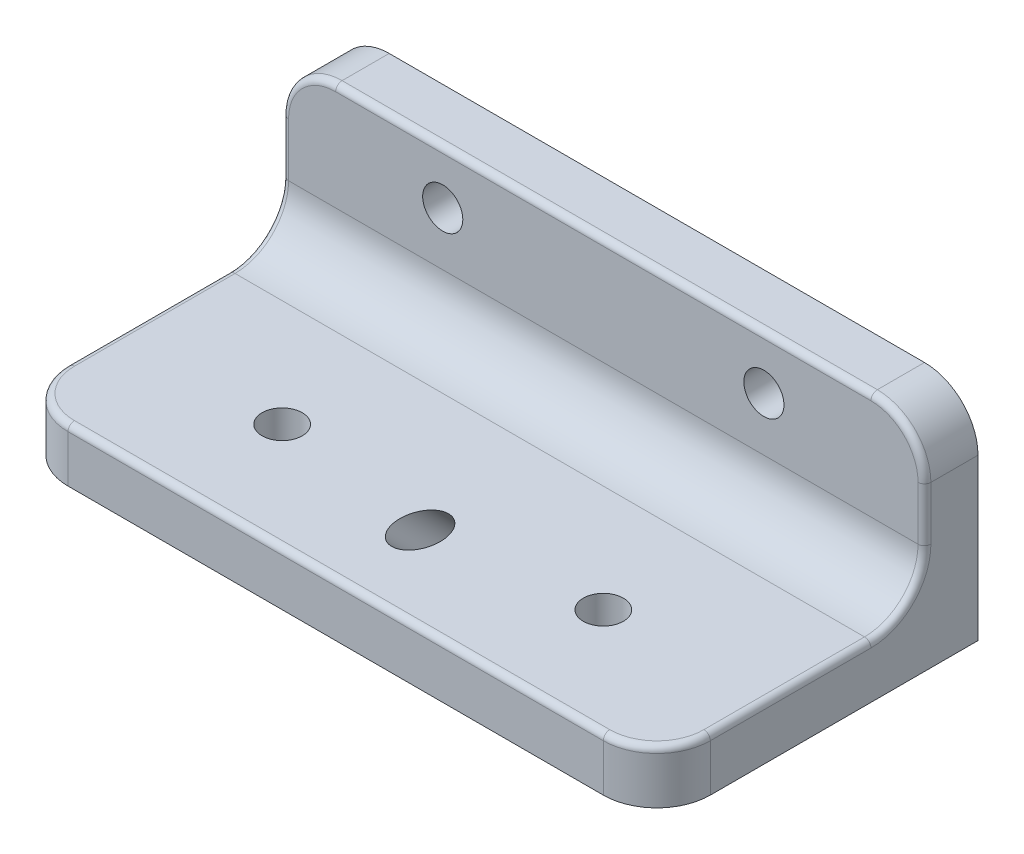
from build123d import *

# Parameters (mm, degrees)
SKETCH1_W           = 38.1
SKETCH1_H           = 12.7
SKETCH1_R           = 1.190625
BOSS_EXTRUDE1_DEPTH = 3.175
SKETCH2_W           = 38.1
SKETCH2_H           = 15.875
BOSS_EXTRUDE2_DEPTH = 3.175
FILLET1_R           = 3.175
FILLET2_R           = 0.381
SKETCH3_R           = 1.190625
CUT_EXTRUDE1_DEPTH  = 16.557632845
SKETCH4_R           = 1.190625
CUT_EXTRUDE2_DEPTH  = 13.7


with BuildPart() as part:
    # Sketch1 → Boss-Extrude1 (new body)
    with BuildSketch(Plane.XY):
        with Locations((19.05, -6.35)):
            Rectangle(SKETCH1_W, SKETCH1_H)
        with Locations((9.525, -3.175)):
            Circle(SKETCH1_R, mode=Mode.SUBTRACT)
        with Locations((28.575, -3.175)):
            Circle(SKETCH1_R, mode=Mode.SUBTRACT)
    extrude(amount=BOSS_EXTRUDE1_DEPTH)

    # Sketch2 → Boss-Extrude2 (add)
    with BuildSketch(Plane(origin=(0, -12.7, 0), x_dir=(-1, 0, 0), z_dir=(0, -1, 0))):
        with Locations((-19.05, -11.1125)):
            Rectangle(SKETCH2_W, SKETCH2_H)
    extrude(amount=-BOSS_EXTRUDE2_DEPTH)

    # Fillet1
    fillet1_edges = [part.edges().sort_by_distance(p)[0] for p in [
        (38.1, 0, 1.5875),
        (0, 0, 1.5875),
        (19.05, -9.525, 3.175),
        (38.1, -11.1125, 19.05),
        (0, -11.1125, 19.05),
    ]]
    fillet(fillet1_edges, radius=FILLET1_R)

    # Fillet2
    fillet2_edges = [part.edges().sort_by_distance(p)[0] for p in [
        (19.05, 0, 3.175),
        (38.1, -4.7625, 3.175),
        (38.1, -9.525, 11.1125),
        (0, -4.7625, 3.175),
        (0.92993597, -0.92993597, 3.175),
        (37.17006403, -0.92993597, 3.175),
        (0, -9.525, 11.1125),
        (19.05, -9.525, 19.05),
        (0.92993597, -9.525, 18.12006403),
        (37.17006403, -9.525, 18.12006403),
        (38.1, -8.59506403, 4.10493597),
        (0, -8.59506403, 4.10493597),
    ]]
    fillet(fillet2_edges, radius=FILLET2_R)

    # Sketch3 → Cut-Extrude1 (cut, through all)
    with BuildSketch(Plane(origin=(0, 4.650907684, 4.650907684), x_dir=(-1, 0, 0), z_dir=(0, 0.707106781, 0.707106781))):
        with Locations((-19.05, 16.664983956)):
            Circle(SKETCH3_R)
    extrude(amount=-CUT_EXTRUDE1_DEPTH, mode=Mode.SUBTRACT)

    # Sketch4 → Cut-Extrude2 (cut, through all)
    with BuildSketch(Plane(origin=(0, -12.7, 0), x_dir=(-1, 0, 0), z_dir=(0, -1, 0))):
        with Locations((-9.525, -12.7)):
            Circle(SKETCH4_R)
        with Locations((-28.575, -12.7)):
            Circle(SKETCH4_R)
    extrude(amount=-CUT_EXTRUDE2_DEPTH, mode=Mode.SUBTRACT)


solid = part.part
